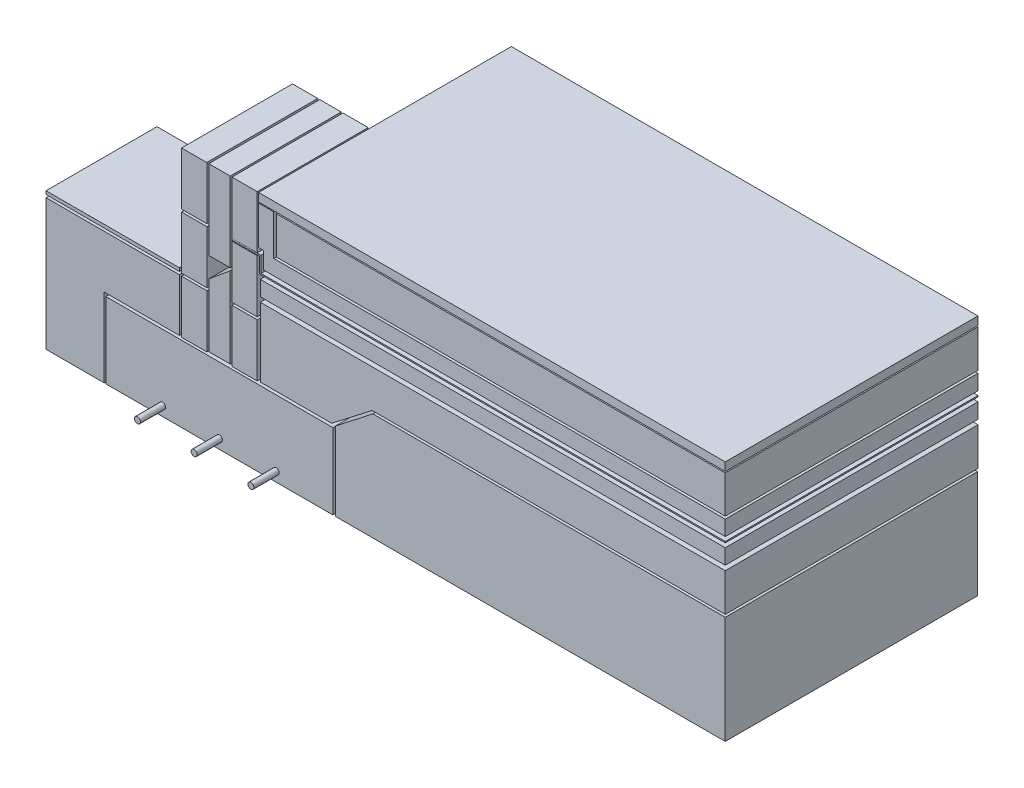
from build123d import *

# Parameters (mm, degrees)
SKETCH1_W        = 900
SKETCH1_H        = 300
EXTRUDE1_DEPTH   = 440
SKETCH2_W        = 100
SKETCH2_H        = 440
EXTRUDE2_DEPTH   = 210
SKETCH3_W        = 100
SKETCH3_H        = 440
EXTRUDE3_DEPTH   = 210
SKETCH4_W        = 100
SKETCH4_H        = 440
EXTRUDE4_DEPTH   = 210
EXTRUDE4_2_DEPTH = 210
SKETCH5_W        = 100
SKETCH5_H        = 440
EXTRUDE5_DEPTH   = 210
EXTRUDE5_2_DEPTH = 210
EXTRUDE7_DEPTH   = 1002
EXTRUDE8_DEPTH   = 440
SKETCH10_W       = 85
SKETCH10_H       = 315.05976919
EXTRUDE9_DEPTH   = 440
EXTRUDE11_DEPTH  = 1000
SKETCH14_W       = 1843.14468312
SKETCH14_H       = 60
EXTRUDE12_DEPTH  = 1002
EXTRUDE13_DEPTH  = 1002
EXTRUDE14_DEPTH  = 1002
SKETCH17_W       = 1779.96582736
SKETCH17_H       = 148.687450901
EXTRUDE15_DEPTH  = 1002
SKETCH18_R       = 12
EXTRUDE16_DEPTH  = 100
SKETCH19_W       = 1849.96582736
SKETCH19_H       = 32.8788738
EXTRUDE17_DEPTH  = 1002
EXTRUDE18_DEPTH  = 440
SKETCH21_W       = 528.678659596
SKETCH21_H       = 12.900889196
EXTRUDE19_DEPTH  = 440


with BuildPart() as part:
    # Sketch1 → Extrude1 (new body)
    with BuildSketch(Plane.XY):
        with Locations((450, 150)):
            Rectangle(SKETCH1_W, SKETCH1_H)
    extrude(amount=-EXTRUDE1_DEPTH)

    # Sketch18 → Extrude16 (add)
    with BuildSketch(Plane.XY):
        with Locations(Location((225, 37.805894922, 0), (0, 0, 180))):  # turned: the seam where the file's is
            Circle(SKETCH18_R)
        with Locations(Location((450, 37.805894922, 0), (0, 0, 180))):  # turned: the seam where the file's is
            Circle(SKETCH18_R)
        with Locations(Location((675, 37.805894922, 0), (0, 0, 180))):  # turned: the seam where the file's is
            Circle(SKETCH18_R)
    extrude(amount=EXTRUDE16_DEPTH)


with BuildPart() as body_2:
    # Sketch2 → Extrude2 (new body)
    with BuildSketch(Plane(origin=(0, 310, 0), x_dir=(-1, 0, 0), z_dir=(0, 1, 0))):
        with Locations((-550, -220)):
            Rectangle(SKETCH2_W, SKETCH2_H)
    extrude(amount=EXTRUDE2_DEPTH)


with BuildPart() as body_3:
    # Sketch3 → Extrude3 (new body)
    with BuildSketch(Plane(origin=(0, 310, 0), x_dir=(-1, 0, 0), z_dir=(0, 1, 0))):
        with Locations((-350, -220)):
            Rectangle(SKETCH3_W, SKETCH3_H)
    extrude(amount=EXTRUDE3_DEPTH)


with BuildPart() as body_4:
    # Sketch4 → Extrude4 (new body)
    with BuildSketch(Plane(origin=(0, 530, 0), x_dir=(-1, 0, 0), z_dir=(0, 1, 0))):
        with Locations((-550, -220)):
            Rectangle(SKETCH4_W, SKETCH4_H)
    extrude(amount=EXTRUDE4_DEPTH)


with BuildPart() as body_5:
    # Sketch4 → Extrude4 2 (new body)
    with BuildSketch(Plane(origin=(0, 530, 0), x_dir=(-1, 0, 0), z_dir=(0, 1, 0))):
        with Locations((-350, -220)):
            Rectangle(SKETCH4_W, SKETCH4_H)
    extrude(amount=EXTRUDE4_2_DEPTH)


with BuildPart() as body_6:
    # Sketch5 → Extrude5 (new body)
    with BuildSketch(Plane(origin=(0, 750, 0), x_dir=(-1, 0, 0), z_dir=(0, 1, 0))):
        with Locations((-550, -220)):
            Rectangle(SKETCH5_W, SKETCH5_H)
    extrude(amount=EXTRUDE5_DEPTH)


with BuildPart() as body_7:
    # Sketch5 → Extrude5 2 (new body)
    with BuildSketch(Plane(origin=(0, 750, 0), x_dir=(-1, 0, 0), z_dir=(0, 1, 0))):
        with Locations((-350, -220)):
            Rectangle(SKETCH5_W, SKETCH5_H)
    extrude(amount=EXTRUDE5_2_DEPTH)


with BuildPart() as body_8:
    # Sketch8 → Extrude7 (new body)
    with BuildSketch(Plane.XY):
        Polygon((612.337272331, 312.339203279), (612.337272331, 586.396879849), (2455.481955451, 586.396879849), (2455.481955451, 436.396879849), (1055.481955451, 436.396879849), (895.481955451, 312.339203279), align=None)
    extrude(amount=-EXTRUDE7_DEPTH)


with BuildPart() as body_9:
    # Sketch9 → Extrude8 (new body)
    with BuildSketch(Plane.XY):
        Polygon((493.044526147, 314.537357653), (493.044526147, 634.537357653), (408.044526147, 564.537357653), (408.044526147, 314.537357653), align=None)
    extrude(amount=-EXTRUDE8_DEPTH)


with BuildPart() as body_10:
    # Sketch10 → Extrude9 (new body)
    with BuildSketch(Plane.XY):
        with Locations((450.544526147, 802.470115405)):
            Rectangle(SKETCH10_W, SKETCH10_H)
    extrude(amount=-EXTRUDE9_DEPTH)


with BuildPart() as body_11:
    # Sketch12 → Extrude11 (new body)
    with BuildSketch(Plane.XY):
        Polygon((910, 0), (910, 310.332457137), (1058.616703881, 426.396879849), (2455.481955451, 426.396879849), (2455.481955451, 0), align=None)
    extrude(amount=-EXTRUDE11_DEPTH)


with BuildPart() as body_12:
    # Sketch14 → Extrude12 (new body)
    with BuildSketch(Plane.XY):
        with Locations((1533.909613891, 635.098199235)):
            Rectangle(SKETCH14_W, SKETCH14_H)
    extrude(amount=-EXTRUDE12_DEPTH)


with BuildPart() as body_13:
    # Sketch15 → Extrude13 (new body)
    with BuildSketch(Plane.XY):
        Polygon((610, 681.76898692), (610, 743.527642329), (499.133684221, 743.527642329), (500, 750), (615, 749.302726066), (615, 686.76898692), (633.64674662, 686.76898692), (2455.481955451, 686.76898692), (2455.481955451, 681.76898692), align=None)
    extrude(amount=-EXTRUDE13_DEPTH)


with BuildPart() as body_14:
    # Sketch16 → Extrude14 (new body)
    with BuildSketch(Plane.XY):
        Polygon((2455.481955451, 703.433675299), (625.562821394, 703.433675299), (625.562821394, 770.727780923), (605.516128091, 770.727780923), (605.516128091, 923.433675299), (665.516128091, 923.433675299), (665.516128091, 763.433675299), (2455.481955451, 763.433675299), align=None)
    extrude(amount=-EXTRUDE14_DEPTH)


with BuildPart() as body_15:
    # Sketch17 → Extrude15 (new body)
    with BuildSketch(Plane.XY):
        with Locations((1565.499041771, 847.777400749)):
            Rectangle(SKETCH17_W, SKETCH17_H)
    extrude(amount=-EXTRUDE15_DEPTH)


with BuildPart() as body_16:
    # Sketch19 → Extrude17 (new body)
    with BuildSketch(Plane.XY):
        with Locations((1530.499041771, 943.5605631)):
            Rectangle(SKETCH19_W, SKETCH19_H)
    extrude(amount=-EXTRUDE17_DEPTH)


with BuildPart() as body_17:
    # Sketch20 → Extrude18 (new body)
    with BuildSketch(Plane.XY):
        Polygon((291.356317511, 312.001587531), (291.356317511, 520.577567847), (-237.322342085, 520.577567847), (-237.322342085, 0), (-6.759554157, 0), (-6.759554157, 312.001587531), align=None)
    extrude(amount=-EXTRUDE18_DEPTH)


with BuildPart() as body_18:
    # Sketch21 → Extrude19 (new body)
    with BuildSketch(Plane.XY):
        with Locations((27.016987713, 538.002607593)):
            Rectangle(SKETCH21_W, SKETCH21_H)
    extrude(amount=-EXTRUDE19_DEPTH)


solid = Compound([part.part, body_2.part, body_3.part, body_4.part, body_5.part, body_6.part, body_7.part, body_8.part, body_9.part, body_10.part, body_11.part, body_12.part, body_13.part, body_14.part, body_15.part, body_16.part, body_17.part, body_18.part])
